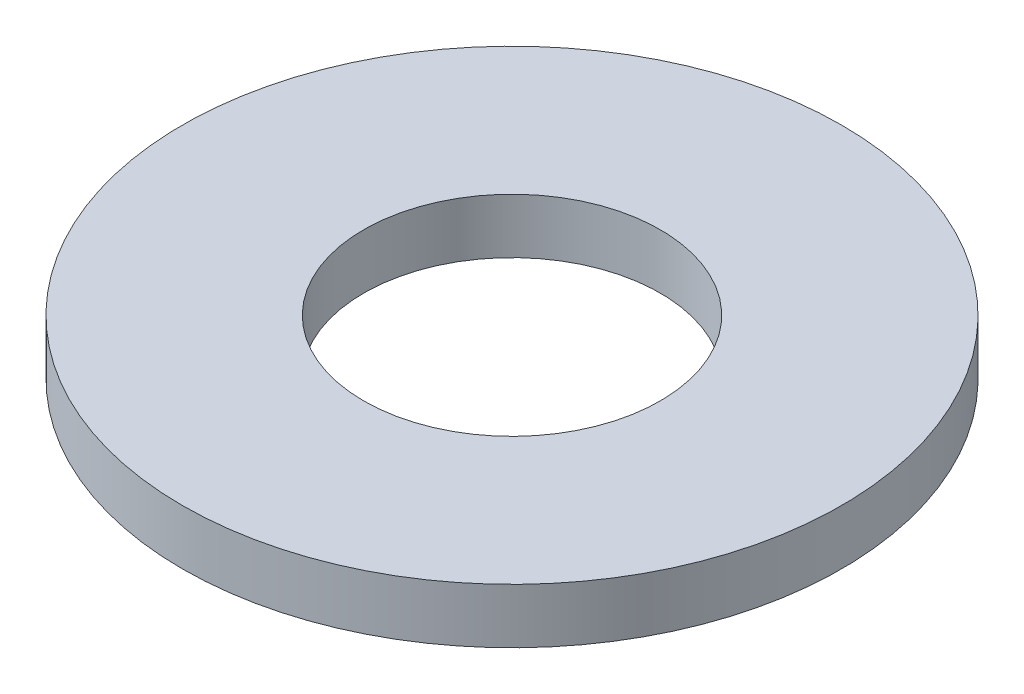
from build123d import *

# Parameters (mm, degrees)
SKETCH1_R           = 9
SKETCH1_R_2         = 4.05
BOSS_EXTRUDE1_DEPTH = 1.5


with BuildPart() as part:
    # Sketch1 → Boss-Extrude1 (new body)
    with BuildSketch(Plane(origin=(0, 0, 0), x_dir=(1, 0, 0), z_dir=(0, 1, 0))):
        Circle(SKETCH1_R)
        Circle(SKETCH1_R_2, mode=Mode.SUBTRACT)
    extrude(amount=BOSS_EXTRUDE1_DEPTH)


solid = part.part
